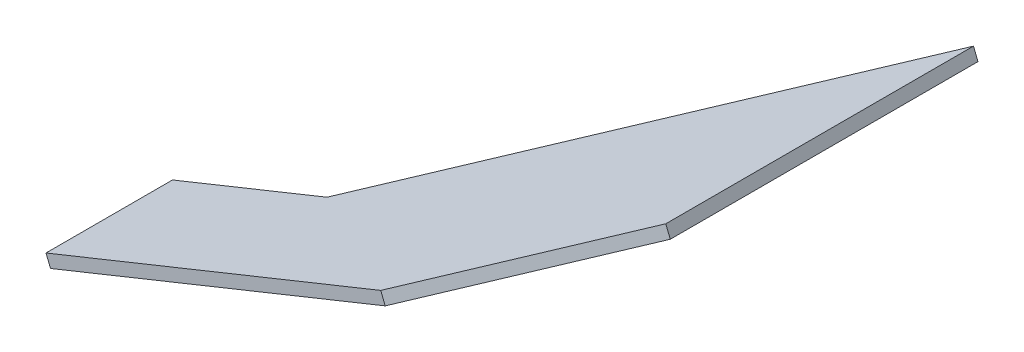
from build123d import *

# Parameters (mm, degrees)
BOSS_EXTRUDE1_DEPTH = 3


with BuildPart() as part:
    # Sketch2 → Boss-Extrude1 (new body)
    with BuildSketch(Plane(origin=(45.890717546, -113.819904614, -1e-08), x_dir=(0.927453922, 0.373937459, 0), z_dir=(0.373937459, -0.927453922, 0))):
        Polygon((7030.729393197, -5519.061989226), (7030.729393197, -5550.552778777), (7072.19399653, -5550.552778777), (7158.729393195, -5631.248341652), (7158.729393195, -5554.642580732), (7120.573880179, -5519.061989226), align=None)
    extrude(amount=BOSS_EXTRUDE1_DEPTH)


solid = part.part
